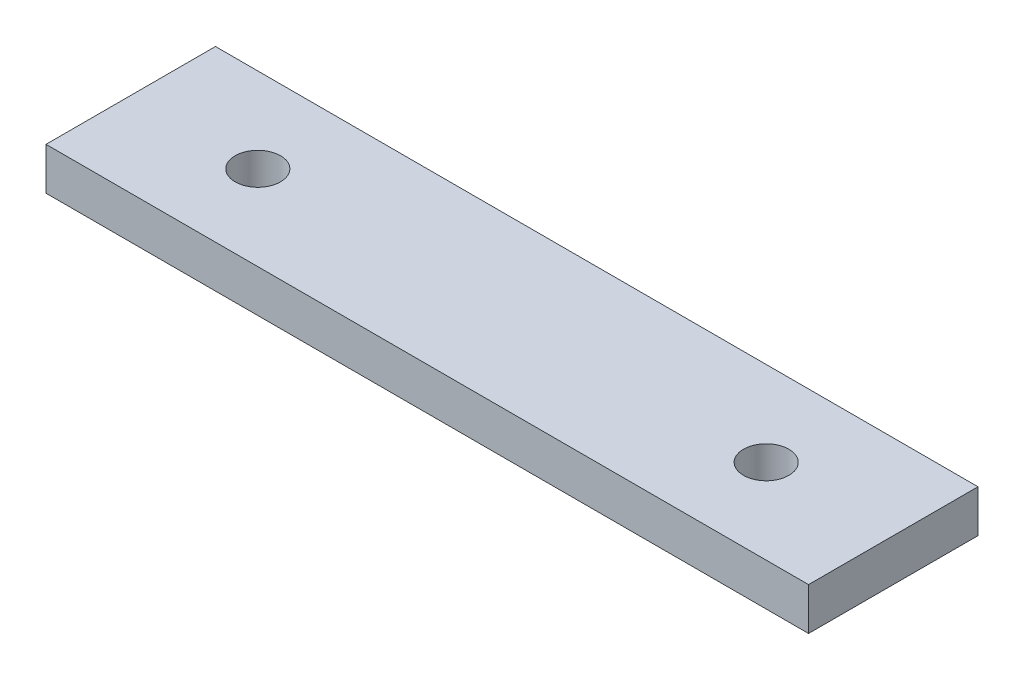
from build123d import *

# Parameters (mm, degrees)
SKETCH1_W           = 114.3
SKETCH1_H           = 25.4
SKETCH1_R           = 3.4
BOSS_EXTRUDE1_DEPTH = 6.35


with BuildPart() as part:
    # Sketch1 → Boss-Extrude1 (new body)
    with BuildSketch(Plane(origin=(0, 0, 0), x_dir=(1, 0, 0), z_dir=(0, 1, 0))):
        Rectangle(SKETCH1_W, SKETCH1_H)
        with Locations((-38.1, 0)):
            Circle(SKETCH1_R, mode=Mode.SUBTRACT)
        with Locations((38.1, 0)):
            Circle(SKETCH1_R, mode=Mode.SUBTRACT)
    extrude(amount=BOSS_EXTRUDE1_DEPTH)


solid = part.part
